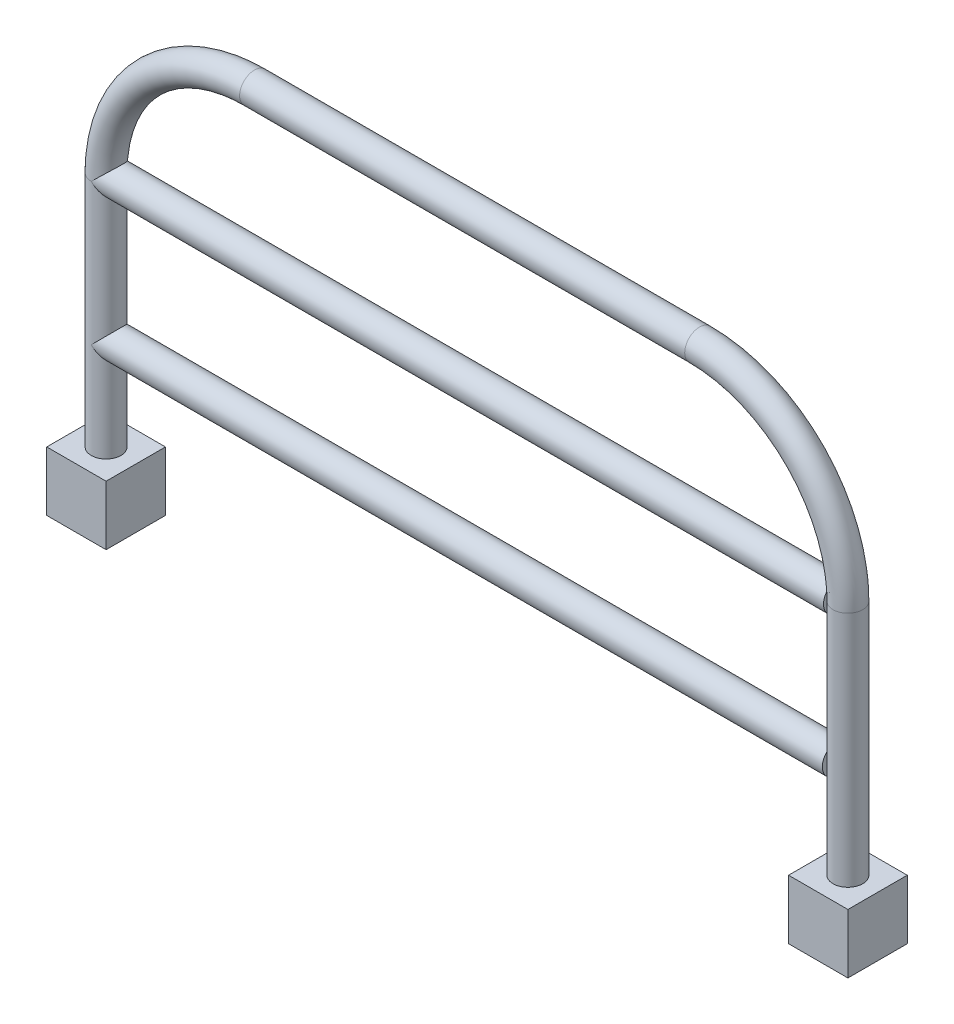
from build123d import *

# Parameters (mm, degrees)
SKETCH2_R           = 12.7
SKETCH3_W           = 50.8
SKETCH3_H           = 50.8
BOSS_EXTRUDE1_DEPTH = 50.8
SKETCH4_R           = 12.7
BOSS_EXTRUDE2_DEPTH = 626.8
SKETCH5_R           = 12.7
BOSS_EXTRUDE3_DEPTH = 625.8


with BuildPart() as part:
    # Sweep1: sweep along a path in Sketch1
    with BuildLine(Plane.XY) as sweep1_path:
        Line((0, 0), (0, 203.2))
        ThreePointArc((0, 203.2), (37.197438789, 293.002561211), (127, 330.2))
        Line((127, 330.2), (508, 330.2))
        ThreePointArc((508, 330.2), (597.802561211, 293.002561211), (635, 203.2))
        Line((635, 203.2), (635, 0))
    # Sketch2 → Sweep1 (sweep)
    with BuildSketch(Plane(origin=(0, 0, 0), x_dir=(1, 0, 0), z_dir=(0, 1, 0))):
        Circle(SKETCH2_R)
    sweep(path=sweep1_path.line)

    # Sketch3 → Boss-Extrude1 (add)
    with BuildSketch(Plane.XZ):
        Rectangle(SKETCH3_W, SKETCH3_H)
        with Locations((635, 0)):
            Rectangle(SKETCH3_W, SKETCH3_H)
    extrude(amount=BOSS_EXTRUDE1_DEPTH)

    # Sketch4 → Boss-Extrude2 (add)
    with BuildSketch(Plane(origin=(0, 0, 0), x_dir=(0, 0, -1), z_dir=(1, 0, 0))):
        with Locations((0, 203.2)):
            Circle(SKETCH4_R)
    extrude(amount=BOSS_EXTRUDE2_DEPTH)

    # Sketch5 → Boss-Extrude3 (add)
    with BuildSketch(Plane(origin=(0, 0, 0), x_dir=(0, 0, -1), z_dir=(1, 0, 0))):
        with Locations((0, 82.09908093)):
            Circle(SKETCH5_R)
    extrude(amount=BOSS_EXTRUDE3_DEPTH)


solid = part.part
